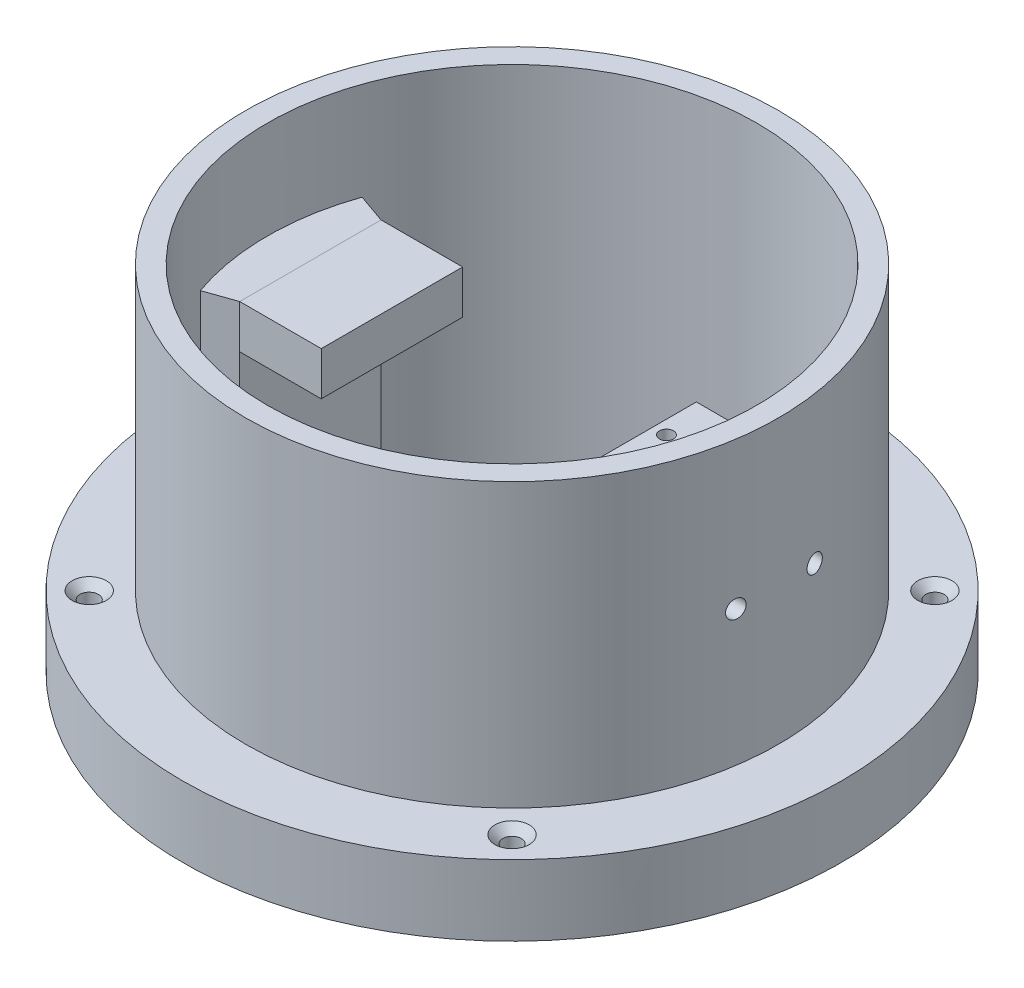
from build123d import *

# Parameters (mm, degrees)
SKETCH1_R                                    = 60.625
SKETCH1_R_2                                  = 45
BOSS_EXTRUDE1_DEPTH                          = 4
SKETCH2_R                                    = 49
SKETCH2_R_2                                  = 45
BOSS_EXTRUDE2_DEPTH                          = 52
SKETCH4_W                                    = 8
SKETCH4_H                                    = 38
BOSS_EXTRUDE4_DEPTH                          = 13
SKETCH4_W_2                                  = 15
SKETCH4_H_2                                  = 8
BOSS_EXTRUDE4_2_DEPTH                        = 13
BOSS_EXTRUDE5_DEPTH                          = 4
SKETCH7_R                                    = 1.3
CUT_EXTRUDE4_DEPTH                           = 7.2
SKETCH9_W                                    = 10
SKETCH9_H                                    = 24
CUT_EXTRUDE7_DEPTH                           = 8
CUT_EXTRUDE9_DEPTH                           = 5
CSK_FOR_M3_COUNTERSUNK_FLAT_HEAD_SCR_2_COUNT = 2
CSK_FOR_M3_COUNTERSUNK_FLAT_HEAD_SCR_2_PITCH = 77.781745931
CSK_FOR_M3_COUNTERSUNK_FLAT_HEAD_SCR_3_COUNT = 2
CSK_FOR_M3_COUNTERSUNK_FLAT_HEAD_SCR_3_PITCH = 110
CSK_FOR_M3_COUNTERSUNK_FLAT_HEAD_SCR_4_COUNT = 2
CSK_FOR_M3_COUNTERSUNK_FLAT_HEAD_SCR_4_PITCH = 77.781745931
SALIENTE_EXTRUIR1_DEPTH                      = 38
SALIENTE_EXTRUIR2_DEPTH                      = 38
CROQUIS7_R                                   = 7.5
CORTAR_EXTRUIR1_DEPTH                        = 38
CROQUIS9_R                                   = 1.65
CORTAR_EXTRUIR2_DEPTH                        = 40.725
CROQUIS12_R                                  = 60.625
CROQUIS12_R_2                                = 45
SALIENTE_EXTRUIR4_DEPTH                      = 9
CROQUIS14_R                                  = 1.7
CORTAR_EXTRUIR4_DEPTH                        = 14


with BuildPart() as part:
    # Sketch1 → Boss-Extrude1 (new body)
    with BuildSketch(Plane(origin=(0, 0, 0), x_dir=(1, 0, 0), z_dir=(0, 1, 0))):
        Circle(SKETCH1_R)
        Circle(SKETCH1_R_2, mode=Mode.SUBTRACT)
    extrude(amount=BOSS_EXTRUDE1_DEPTH)

    # Sketch2 → Boss-Extrude2 (add)
    with BuildSketch(Plane(origin=(0, 4, 0), x_dir=(1, 0, 0), z_dir=(0, 1, 0))):
        Circle(SKETCH2_R)
        Circle(SKETCH2_R_2, mode=Mode.SUBTRACT)
    extrude(amount=BOSS_EXTRUDE2_DEPTH)



with BuildPart() as body_2:
    # Sketch4 → Boss-Extrude4 (new body, symmetric)
    with BuildSketch(Plane.XY):
        with Locations((24.9, 19)):
            Rectangle(SKETCH4_W, SKETCH4_H)
    extrude(amount=BOSS_EXTRUDE4_DEPTH, both=True)


with BuildPart() as body_3:
    # Sketch4 → Boss-Extrude4 2 (new body, symmetric)
    with BuildSketch(Plane.XY):
        with Locations((-29.6, 34)):
            Rectangle(SKETCH4_W_2, SKETCH4_H_2)
    extrude(amount=BOSS_EXTRUDE4_2_DEPTH, both=True)


with BuildPart() as part_1:
    add(part.part)

    add(body_2.part)  # Boss-Extrude5 merges body 2
    # Sketch5 → Boss-Extrude5 (add)
    with BuildSketch(Plane.XZ):
        with BuildLine():
            Line((20.9, 13), (29.067400866, 34.352382842))
            ThreePointArc((29.067400866, 34.352382842), (45, 0), (29.067400866, -34.352382842))
            Line((29.067400866, -34.352382842), (20.9, -13))
            Line((20.9, -13), (20.9, 13))
        make_face()
    extrude(amount=-BOSS_EXTRUDE5_DEPTH)

    # Sketch7 → Cut-Extrude4 (cut)
    with BuildSketch(Plane(origin=(0, 38, 0), x_dir=(1, 0, 0), z_dir=(0, 1, 0))):
        with Locations((-24.6, 5)):
            Circle(SKETCH7_R)
        with Locations((-24.6, -5)):
            Circle(SKETCH7_R)
        with Locations((23.4, 5)):
            Circle(SKETCH7_R)
        with Locations((23.4, -5)):
            Circle(SKETCH7_R)
    extrude(amount=-CUT_EXTRUDE4_DEPTH, mode=Mode.SUBTRACT)

    # Sketch9 → Cut-Extrude7 (cut)
    with BuildSketch(Plane.ZY.offset(-20.9)):
        with Locations((0, 17)):
            Rectangle(SKETCH9_W, SKETCH9_H)
    extrude(amount=-CUT_EXTRUDE7_DEPTH, mode=Mode.SUBTRACT)

    # Sketch12 → Cut-Extrude9 (cut, through all)
    with BuildSketch(Plane(origin=(0, 4, 0), x_dir=(1, 0, 0), z_dir=(0, 1, 0))):
        with BuildLine():
            ThreePointArc((36.9, -2.718455444), (37, 0), (36.9, 2.718455444))
            Line((36.9, 2.718455444), (36.9, -2.718455444))
        make_face()
        with BuildLine():
            ThreePointArc((29.067400866, -34.352382842), (40.822990085, -18.933659987), (45, 0))
            ThreePointArc((45, 0), (40.822990085, 18.933659987), (29.067400866, 34.352382842))
            Line((29.067400866, 34.352382842), (20.9, 13))
            Line((20.9, 13), (28.9, 13))
            Line((28.9, 13), (28.9, -13))
            Line((28.9, -13), (20.9, -13))
            Line((20.9, -13), (29.067400866, -34.352382842))
        make_face()
        with BuildLine():
            Line((36.9, -2.718455444), (36.9, 2.718455444))
            ThreePointArc((36.9, 2.718455444), (37, 0), (36.9, -2.718455444))
        make_face(mode=Mode.SUBTRACT)
    extrude(amount=-CUT_EXTRUDE9_DEPTH, mode=Mode.SUBTRACT)

    # Sketch17 → CSK for M3 Countersunk Flat Head Screw1 (revolve, cut)
    with BuildSketch(Plane(origin=(-38.890872965, 4, -38.890872965), x_dir=(0, 0, 1), z_dir=(1, 0, 0))):
        Polygon((0, 0), (0, 4.001), (1.7, 4.001), (1.7, 1.45), (3.15, 0), align=None)
    csk_for_m3_countersunk_flat_head_screw1 = revolve(axis=Axis((-38.890872965, 10.35, -38.890872965), (0, -1, 0)), mode=Mode.SUBTRACT)

    # CSK for M3 Countersunk Flat Head Scr 2: CSK for M3 Countersunk Flat Head Screw1 ×2
    with Locations(*[(0, 0, i * CSK_FOR_M3_COUNTERSUNK_FLAT_HEAD_SCR_2_PITCH) for i in range(1, CSK_FOR_M3_COUNTERSUNK_FLAT_HEAD_SCR_2_COUNT)]):
        add(csk_for_m3_countersunk_flat_head_screw1, mode=Mode.SUBTRACT)

    # CSK for M3 Countersunk Flat Head Scr 3: CSK for M3 Countersunk Flat Head Screw1 ×2
    with Locations(*[Vector(0.707106781, 0, 0.707106781) * (i * CSK_FOR_M3_COUNTERSUNK_FLAT_HEAD_SCR_3_PITCH) for i in range(1, CSK_FOR_M3_COUNTERSUNK_FLAT_HEAD_SCR_3_COUNT)]):
        add(csk_for_m3_countersunk_flat_head_screw1, mode=Mode.SUBTRACT)

    # CSK for M3 Countersunk Flat Head Scr 4: CSK for M3 Countersunk Flat Head Screw1 ×2
    with Locations(*[(i * CSK_FOR_M3_COUNTERSUNK_FLAT_HEAD_SCR_4_PITCH, 0, 0) for i in range(1, CSK_FOR_M3_COUNTERSUNK_FLAT_HEAD_SCR_4_COUNT)]):
        add(csk_for_m3_countersunk_flat_head_screw1, mode=Mode.SUBTRACT)

    # Croquis3 → Saliente-Extruir1 (add)
    with BuildSketch(Plane.XZ):
        Polygon((28.9, 13), (41.02948985, 18.481909063), (41.039124346, -18.460505761), (28.9, -13), align=None)
        with BuildLine():
            Line((-37.1, 13), (-42.468269464, 14.881064772))
            ThreePointArc((-42.468269464, 14.881064772), (-45, 0), (-42.468269464, -14.881064772))
            Line((-42.468269464, -14.881064772), (-37.1, -13))
            Line((-37.1, -13), (-37.1, 13))
        make_face()
    extrude(amount=-SALIENTE_EXTRUIR1_DEPTH)

    # Croquis6 → Saliente-Extruir2 (add)
    with BuildSketch(Plane(origin=(0, 0, 0), x_dir=(1, 0, 0), z_dir=(0, 1, 0))):
        Polygon((41.039124346, 18.460505761), (43.840051606, 18.460505761), (46.523602828, 6.268088211), (46.523602828, -4.665099601), (45, -15.515113827), (44.583260481, -18.482835878), (41.02948985, -18.481909063), align=None)
    extrude(amount=SALIENTE_EXTRUIR2_DEPTH)

    # Croquis7 → Cortar-Extruir1 (cut)
    with BuildSketch(Plane.XZ):
        with Locations((34.115531068, 0)):
            Circle(CROQUIS7_R)
    extrude(amount=-CORTAR_EXTRUIR1_DEPTH, mode=Mode.SUBTRACT)

    # Croquis9 → Cortar-Extruir2 (cut, through all)
    with BuildSketch(Plane.ZY.offset(-20.9)):
        with Locations((-7.23, 28.95)):
            Circle(CROQUIS9_R)
        with Locations((7.27, 28.95)):
            Circle(CROQUIS9_R)
    extrude(amount=-CORTAR_EXTRUIR2_DEPTH, mode=Mode.SUBTRACT)

    # Croquis12 → Saliente-Extruir4 (add)
    with BuildSketch(Plane.XZ):
        Circle(CROQUIS12_R)
        Circle(CROQUIS12_R_2, mode=Mode.SUBTRACT)
    extrude(amount=SALIENTE_EXTRUIR4_DEPTH)

    # Croquis14 → Cortar-Extruir4 (cut, through all)
    with BuildSketch(Plane(origin=(0, 4, 0), x_dir=(1, 0, 0), z_dir=(0, 1, 0))):
        with Locations((-38.890872965, 38.890872965)):
            Circle(CROQUIS14_R)
        with Locations((38.890872965, 38.890872965)):
            Circle(CROQUIS14_R)
        with Locations((38.890872965, -38.890872965)):
            Circle(CROQUIS14_R)
        with Locations((-38.890872965, -38.890872965)):
            Circle(CROQUIS14_R)
    extrude(amount=-CORTAR_EXTRUIR4_DEPTH, mode=Mode.SUBTRACT)


solid = Compound([body_3.part, part_1.part])
